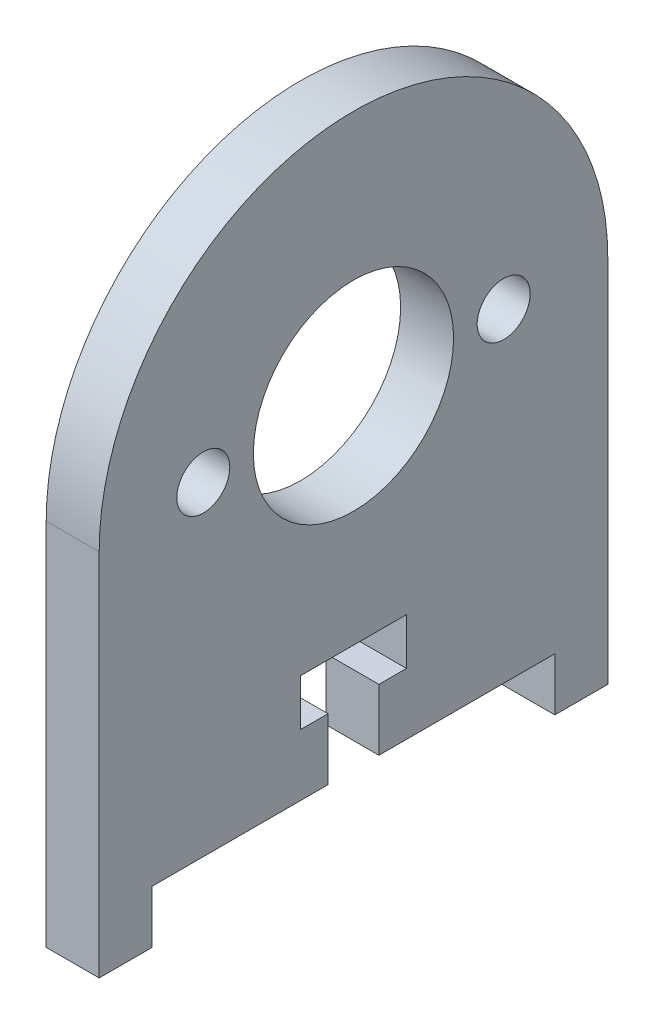
from build123d import *

# Parameters (mm, degrees)
SKETCH1_R           = 6
SKETCH1_R_2         = 1.5875
BOSS_EXTRUDE1_DEPTH = 3.175


with BuildPart() as part:
    # Sketch1 → Boss-Extrude1 (new body)
    with BuildSketch(Plane(origin=(0, 0, 0), x_dir=(0, 0, -1), z_dir=(1, 0, 0))):
        with BuildLine():
            Line((-13.716, -3.175), (-13.716, 18.94882794))
            ThreePointArc((-13.716, 18.94882794), (1.524, 34.18882794), (16.764, 18.94882794))
            Line((16.764, 18.94882794), (16.764, -3.175))
            Line((16.764, -3.175), (13.589, -3.175))
            Line((13.589, -3.175), (13.589, 0))
            Line((13.589, 0), (3.048, 0))
            Line((3.048, 0), (3.048, 3.683))
            Line((3.048, 3.683), (4.699, 3.683))
            Line((4.699, 3.683), (4.699, 6.477))
            Line((4.699, 6.477), (-1.651, 6.477))
            Line((-1.651, 6.477), (-1.651, 3.683))
            Line((-1.651, 3.683), (0, 3.683))
            Line((0, 3.683), (0, 0))
            Line((0, 0), (-10.541, 0))
            Line((-10.541, 0), (-10.541, -3.175))
            Line((-10.541, -3.175), (-13.716, -3.175))
        make_face()
        with Locations((1.524, 19.423957259)):
            Circle(SKETCH1_R, mode=Mode.SUBTRACT)
        with Locations((-7.476, 19.423957259)):
            Circle(SKETCH1_R_2, mode=Mode.SUBTRACT)
        with Locations((10.524, 19.423957259)):
            Circle(SKETCH1_R_2, mode=Mode.SUBTRACT)
    extrude(amount=BOSS_EXTRUDE1_DEPTH)


solid = part.part
